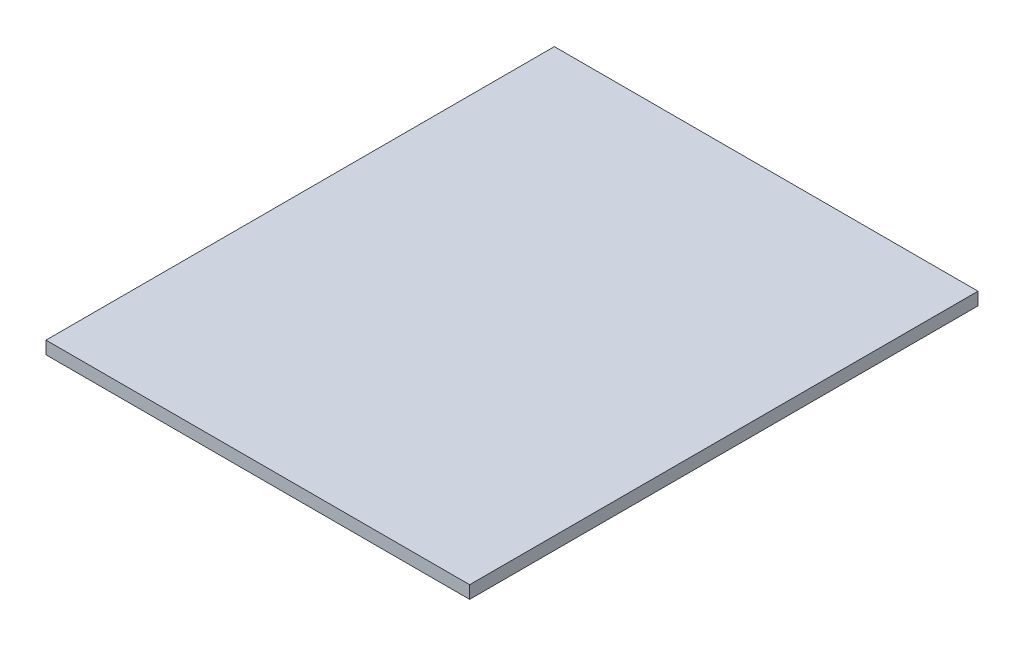
from build123d import *

# Parameters (mm, degrees)
SKETCH1_W           = 381
SKETCH1_H           = 457.2
BOSS_EXTRUDE1_DEPTH = 11.4554


with BuildPart() as part:
    # Sketch1 → Boss-Extrude1 (new body)
    with BuildSketch(Plane(origin=(0, 0, 0), x_dir=(1, 0, 0), z_dir=(0, 1, 0))):
        Rectangle(SKETCH1_W, SKETCH1_H)
    extrude(amount=BOSS_EXTRUDE1_DEPTH)


solid = part.part
